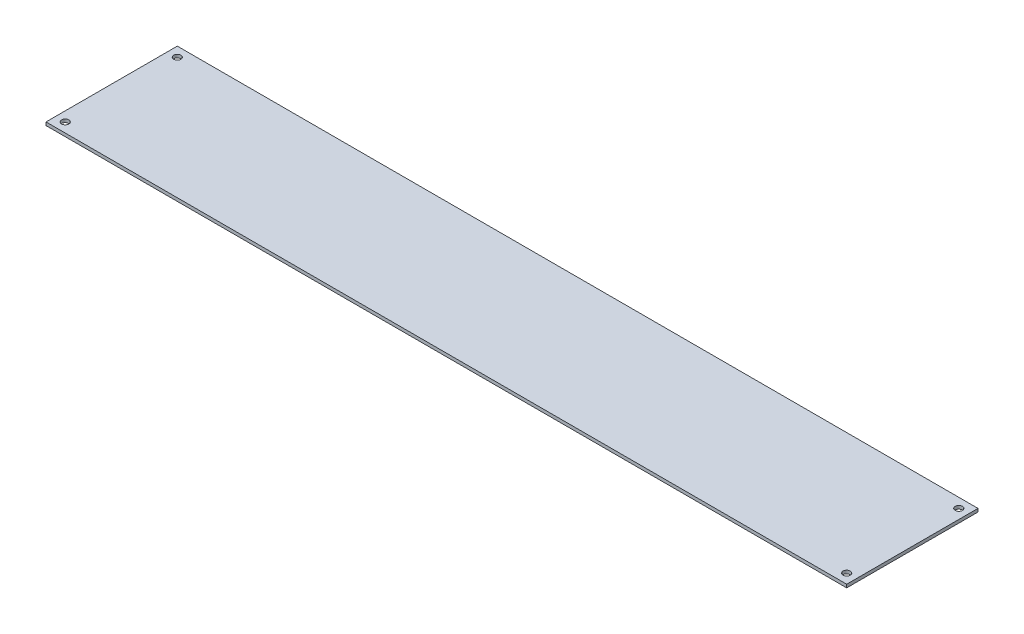
from build123d import *

# Parameters (mm, degrees)
SKETCH1_W                = 500
SKETCH1_H                = 82
BOSS_EXTRUDE1_DEPTH      = 2
M4_CLEARANCE_HOLE1_D     = 4.5
M4_CLEARANCE_HOLE1_DEPTH = 2


with BuildPart() as part:
    # Sketch1 → Boss-Extrude1 (new body)
    with BuildSketch(Plane(origin=(0, 0, 0), x_dir=(1, 0, 0), z_dir=(0, 1, 0))):
        with Locations((250, 41)):
            Rectangle(SKETCH1_W, SKETCH1_H)
    extrude(amount=BOSS_EXTRUDE1_DEPTH)

    # M4 Clearance Hole1
    with Locations(Plane(origin=(0, 0, 0), x_dir=(-1, 0, 0), z_dir=(0, -1, 0))):
        with Locations((-6, 6), (-6, 76), (-494, 76), (-494, 6)):
            Hole(M4_CLEARANCE_HOLE1_D / 2, depth=M4_CLEARANCE_HOLE1_DEPTH)


solid = part.part
